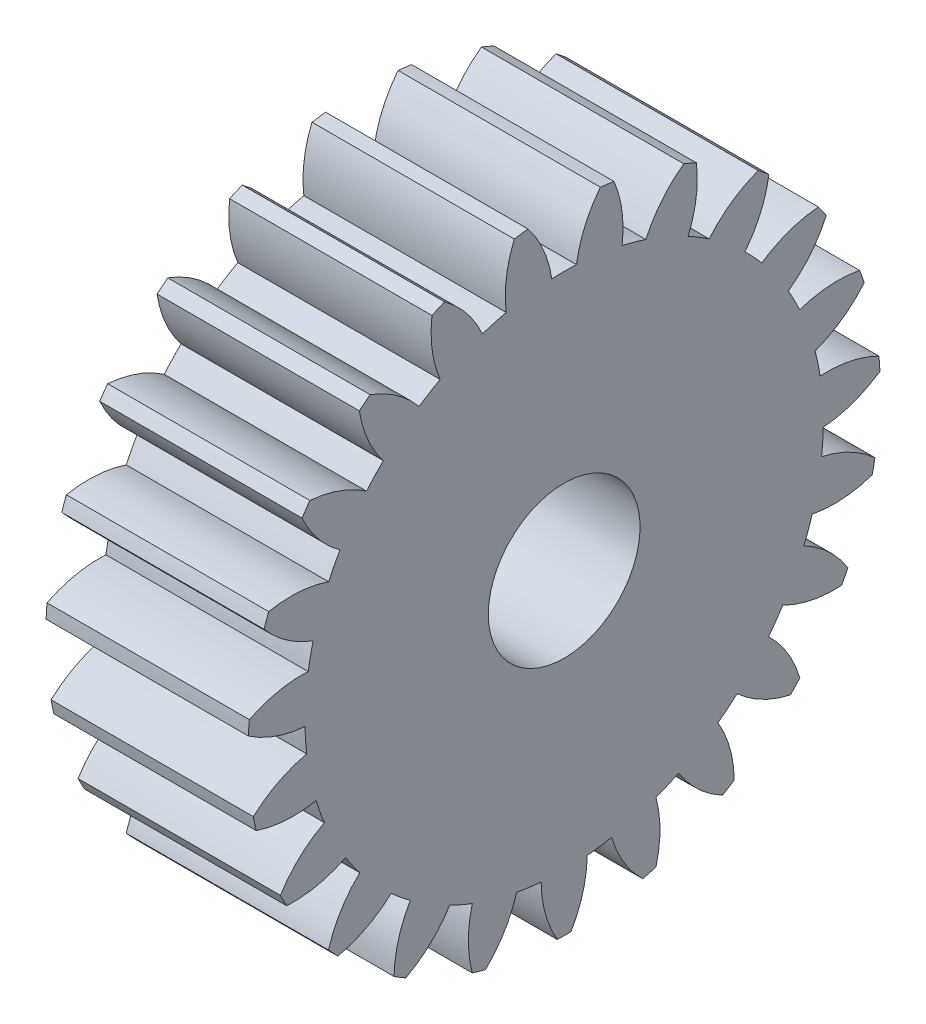
from build123d import *

# Parameters (mm, degrees)
BASPROSKE_W     = 8
BASPROSKE_H     = 12.5
TOOTHCUT_DEPTH  = 20.403607912
TEETHCUTS_COUNT = 23
TEETHCUTS_ANGLE = 344.347826087
BORSKE_R        = 3
BORE_DEPTH      = 50.0000508


with BuildPart() as part:
    # BasProSke → Base-Revolve (revolve)
    with BuildSketch(Plane(origin=(0, 0, 0), x_dir=(1, 0, 0), z_dir=(0, 1, 0)), mode=Mode.PRIVATE) as base_revolve_sk:
        with Locations((4, 6.25)):
            Rectangle(BASPROSKE_W, BASPROSKE_H)
    revolve(base_revolve_sk.sketch.rotate(Axis((-10, 0, 0), (1, 0, 0)), 180), axis=Axis((-10, 0, 0), (1, 0, 0)))

    # TooCutSke → ToothCut (cut, through all)
    with BuildSketch(Plane(origin=(0, 0, 0), x_dir=(0, 0, -1), z_dir=(1, 0, 0))):
        with BuildLine():
            ThreePointArc((0.487075069, 10.237419542), (0, 10.249), (-0.487075069, 10.237419542))
            ThreePointArc((-0.487075069, 10.237419542), (-0.822200209, 11.403353821), (-1.450473694, 12.441132232))
            ThreePointArc((-1.450473694, 12.441132232), (0, 12.5254), (1.450473694, 12.441132232))
            ThreePointArc((1.450473694, 12.441132232), (0.822200209, 11.403353821), (0.487075069, 10.237419542))
        make_face()
    toothcut = extrude(amount=TOOTHCUT_DEPTH, mode=Mode.SUBTRACT)

    # TeethCuts: ToothCut ×23 about axis
    teethcuts_axis = Axis((-10, 0, 0), (1, 0, 0))
    for i in range(1, TEETHCUTS_COUNT):
        add(toothcut.rotate(teethcuts_axis, i * TEETHCUTS_ANGLE / (TEETHCUTS_COUNT - 1)), mode=Mode.SUBTRACT)

    # BorSke → Bore (cut, symmetric)
    with BuildSketch(Plane(origin=(0, 0, 0), x_dir=(0, 0, -1), z_dir=(1, 0, 0))):
        with Locations(Location((0, 0, 0), (0, 0, 180))):
            Circle(BORSKE_R)
    extrude(amount=BORE_DEPTH, both=True, mode=Mode.SUBTRACT)


solid = part.part
